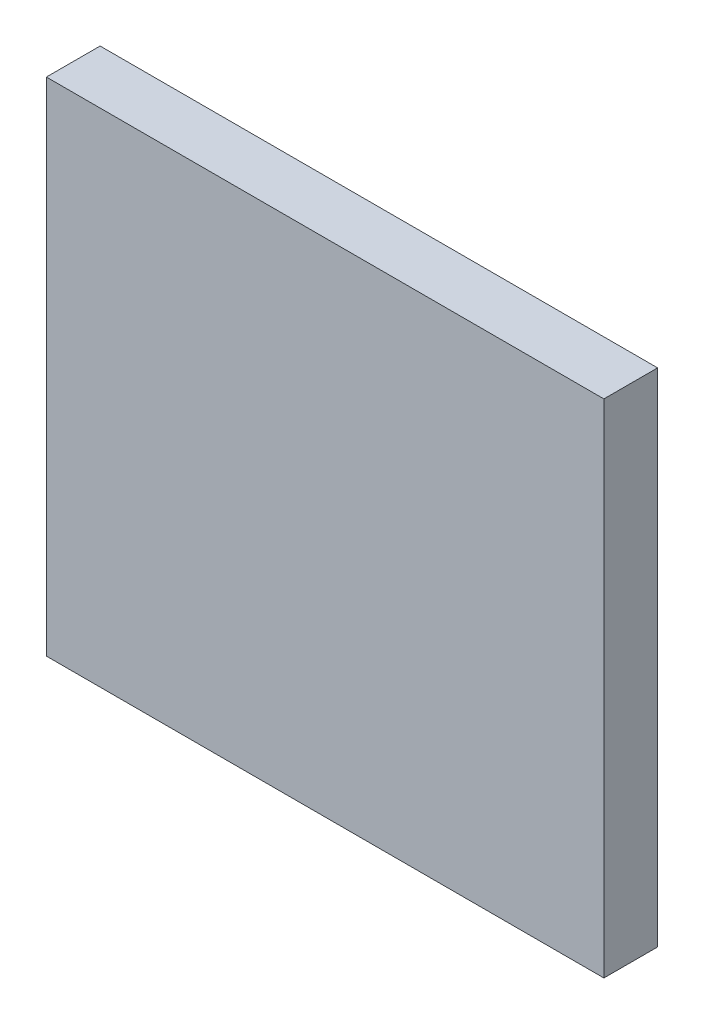
from build123d import *

# Parameters (mm, degrees)
ESQUISSE1_W        = 124.5
ESQUISSE1_H        = 112
BOSS_EXTRU_1_DEPTH = 12


with BuildPart() as part:
    # Esquisse1 → Boss.-Extru.1 (new body)
    with BuildSketch(Plane.XY):
        with Locations((-62.25, 56)):
            Rectangle(ESQUISSE1_W, ESQUISSE1_H)
    extrude(amount=BOSS_EXTRU_1_DEPTH)


solid = part.part
